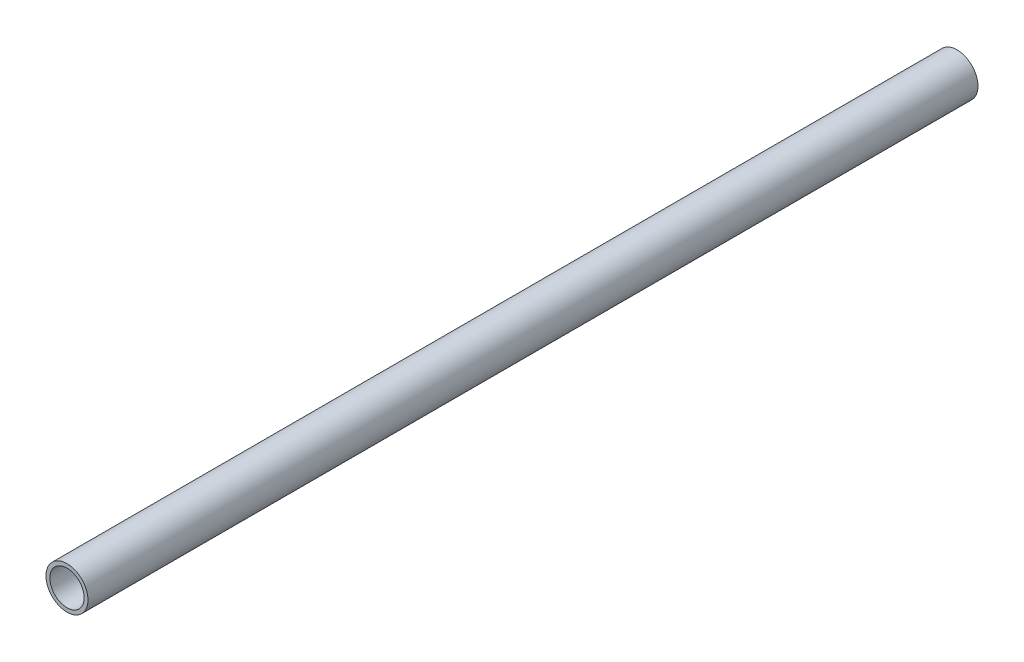
from build123d import *

# Parameters (mm, degrees)
SKETCH2_R           = 3.825
SKETCH2_R_2         = 3.125
BOSS_EXTRUDE1_DEPTH = 81


with BuildPart() as part:
    # Sketch2 → Boss-Extrude1 (new body, symmetric)
    with BuildSketch(Plane.XY):
        Circle(SKETCH2_R)
        Circle(SKETCH2_R_2, mode=Mode.SUBTRACT)
    extrude(amount=BOSS_EXTRUDE1_DEPTH, both=True)


solid = part.part
